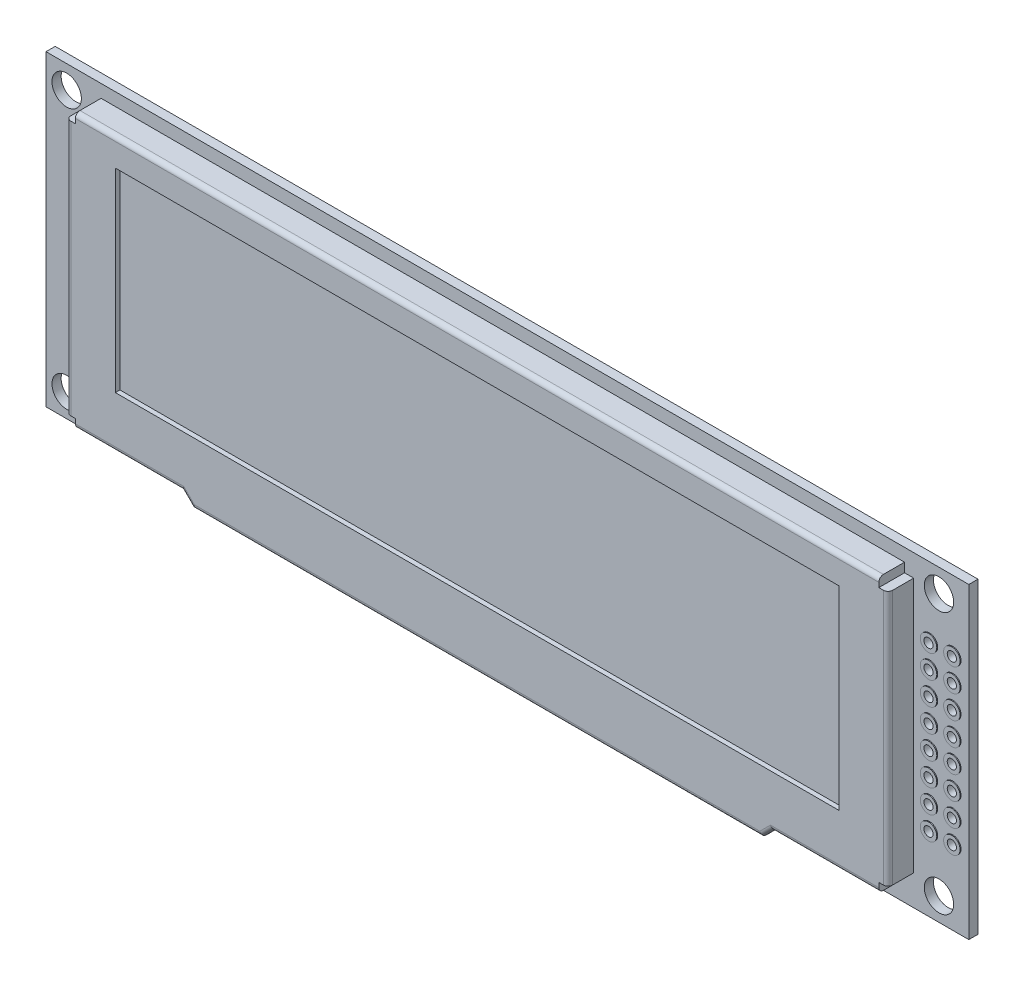
from build123d import *

# Parameters (mm, degrees)
SKETCH_1_W          = 100.5
SKETCH_1_H          = 33.5
SKETCH_1_R          = 1.6
EXTRUDE_1_DEPTH     = 1
EXTRUDE_2_DEPTH     = 2.8
FILLET_1_R          = 0.5
SKETCH_3_W          = 78.8
SKETCH_3_H          = 21.18
CUT_EXTRUDE_1_DEPTH = 0.5
SKETCH_4_R          = 0.9
EXTRUDE_3_DEPTH     = 0.1
SKETCH_5_R          = 0.5
CUT_EXTRUDE_2_DEPTH = 2.1


with BuildPart() as part:
    # Эскиз1 → Бобышка-Вытянуть1 (new body)
    with BuildSketch(Plane.XY):
        Rectangle(SKETCH_1_W, SKETCH_1_H)
        with Locations((-48, 14.25)):
            Circle(SKETCH_1_R, mode=Mode.SUBTRACT)
        with Locations((47, 14.25)):
            Circle(SKETCH_1_R, mode=Mode.SUBTRACT)
        with Locations((47, -14.25)):
            Circle(SKETCH_1_R, mode=Mode.SUBTRACT)
        with Locations((-48, -14.25)):
            Circle(SKETCH_1_R, mode=Mode.SUBTRACT)
    extrude(amount=EXTRUDE_1_DEPTH)

    # Эскиз2 → Бобышка-Вытянуть2 (add)
    with BuildSketch(Plane.XY.offset(1)):
        Polygon((43.25, 15.35), (-44.25, 15.35), (-44.25, 14.35), (-45.25, 14.35), (-45.25, -13.45), (-44.25, -13.45), (-44.25, -14.45), (-32.65, -14.45), (-31.5, -15.6), (30.5, -15.6), (31.65, -14.45), (43.25, -14.45), (43.25, -13.45), (44.25, -13.45), (44.25, 14.35), (43.25, 14.35), align=None)
    extrude(amount=EXTRUDE_2_DEPTH)

    # Скругление1
    fillet_1_edges = [part.edges().sort_by_distance(p)[0] for p in [
        (-45.25, 0.45, 3.8),
        (-38.45, -14.45, 3.8),
        (-32.075, -15.025, 3.8),
        (-0.5, -15.6, 3.8),
        (31.075, -15.025, 3.8),
        (37.45, -14.45, 3.8),
        (44.25, 0.45, 3.8),
        (-0.5, 15.35, 3.8),
    ]]
    fillet(fillet_1_edges, radius=FILLET_1_R)

    # Эскиз3 → Вырез-Вытянуть1 (cut)
    with BuildSketch(Plane.XY.offset(3.8)):
        with Locations((-0.5, 1.76)):
            Rectangle(SKETCH_3_W, SKETCH_3_H)
    extrude(amount=-CUT_EXTRUDE_1_DEPTH, mode=Mode.SUBTRACT)

    # Эскиз4 → Бобышка-Вытянуть3 (add)
    with BuildSketch(Plane.XY.offset(1)):
        with Locations((48.5, -8.64)):
            Circle(SKETCH_4_R)
        with Locations((45.96, -8.64)):
            Circle(SKETCH_4_R)
        with Locations((45.96, -6.1)):
            Circle(SKETCH_4_R)
        with Locations((45.96, -3.56)):
            Circle(SKETCH_4_R)
        with Locations((45.96, -1.02)):
            Circle(SKETCH_4_R)
        with Locations((45.96, 1.52)):
            Circle(SKETCH_4_R)
        with Locations((45.96, 4.06)):
            Circle(SKETCH_4_R)
        with Locations((45.96, 6.6)):
            Circle(SKETCH_4_R)
        with Locations((45.96, 9.14)):
            Circle(SKETCH_4_R)
        with Locations((48.5, -6.1)):
            Circle(SKETCH_4_R)
        with Locations((48.5, -3.56)):
            Circle(SKETCH_4_R)
        with Locations((48.5, -1.02)):
            Circle(SKETCH_4_R)
        with Locations((48.5, 1.52)):
            Circle(SKETCH_4_R)
        with Locations((48.5, 4.06)):
            Circle(SKETCH_4_R)
        with Locations((48.5, 6.6)):
            Circle(SKETCH_4_R)
        with Locations((48.5, 9.14)):
            Circle(SKETCH_4_R)
    extrude(amount=EXTRUDE_3_DEPTH)

    # Эскиз5 → Вырез-Вытянуть2 (cut, through all)
    with BuildSketch(Plane.XY.offset(1.1)):
        with Locations((48.5, -8.64)):
            Circle(SKETCH_5_R)
        with Locations((45.96, -8.64)):
            Circle(SKETCH_5_R)
        with Locations((45.96, -6.1)):
            Circle(SKETCH_5_R)
        with Locations((45.96, -3.56)):
            Circle(SKETCH_5_R)
        with Locations((45.96, -1.02)):
            Circle(SKETCH_5_R)
        with Locations((45.96, 1.52)):
            Circle(SKETCH_5_R)
        with Locations((45.96, 4.06)):
            Circle(SKETCH_5_R)
        with Locations((45.96, 6.6)):
            Circle(SKETCH_5_R)
        with Locations((45.96, 9.14)):
            Circle(SKETCH_5_R)
        with Locations((48.5, -6.1)):
            Circle(SKETCH_5_R)
        with Locations((48.5, -3.56)):
            Circle(SKETCH_5_R)
        with Locations((48.5, -1.02)):
            Circle(SKETCH_5_R)
        with Locations((48.5, 1.52)):
            Circle(SKETCH_5_R)
        with Locations((48.5, 4.06)):
            Circle(SKETCH_5_R)
        with Locations((48.5, 6.6)):
            Circle(SKETCH_5_R)
        with Locations((48.5, 9.14)):
            Circle(SKETCH_5_R)
    extrude(amount=-CUT_EXTRUDE_2_DEPTH, mode=Mode.SUBTRACT)


solid = part.part
